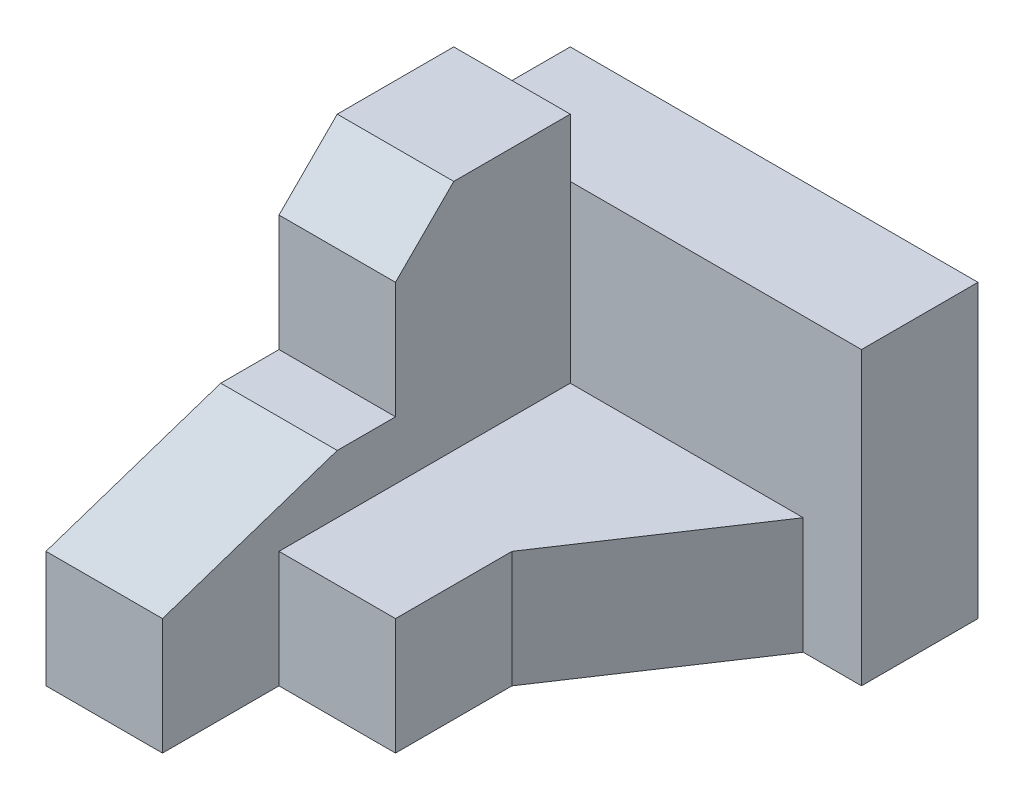
from build123d import *

# Parameters (mm, degrees)
BOSS_EXTRUDE1_DEPTH = 2
BOSS_EXTRUDE2_DEPTH = 3
SKETCH3_W           = 2
SKETCH3_H           = 3
BOSS_EXTRUDE3_DEPTH = 1
CUT_EXTRUDE1_DEPTH  = 3


with BuildPart() as part:
    # Sketch1 → Boss-Extrude1 (new body)
    with BuildSketch(Plane(origin=(0, 0, 0), x_dir=(1, 0, 0), z_dir=(0, 1, 0))):
        Polygon((0, 0), (2, 0), (2, 2), (4, 2), (4, 4), (6, 7), (7, 7), (7, 9), (0, 9), align=None)
    extrude(amount=BOSS_EXTRUDE1_DEPTH)

    # Sketch2 → Boss-Extrude2 (add)
    with BuildSketch(Plane(origin=(0, 2, 0), x_dir=(1, 0, 0), z_dir=(0, 1, 0))):
        Polygon((7, 9), (0, 9), (0, 0), (2, 0), (2, 7), (7, 7), align=None)
    extrude(amount=BOSS_EXTRUDE2_DEPTH)

    # Sketch3 → Boss-Extrude3 (add)
    with BuildSketch(Plane(origin=(0, 5, 0), x_dir=(1, 0, 0), z_dir=(0, 1, 0))):
        with Locations((1, 5.5)):
            Rectangle(SKETCH3_W, SKETCH3_H)
    extrude(amount=BOSS_EXTRUDE3_DEPTH)

    # Sketch4 → Cut-Extrude1 (cut, through all)
    with BuildSketch(Plane(origin=(2, 0, 0), x_dir=(0, 0, -1), z_dir=(1, 0, 0))):
        Polygon((4, 5), (5, 6), (4, 6), align=None)
        Polygon((4, 3), (4, 5), (0, 5), (0, 2), (3, 3), align=None)
    extrude(amount=-CUT_EXTRUDE1_DEPTH, mode=Mode.SUBTRACT)


solid = part.part
